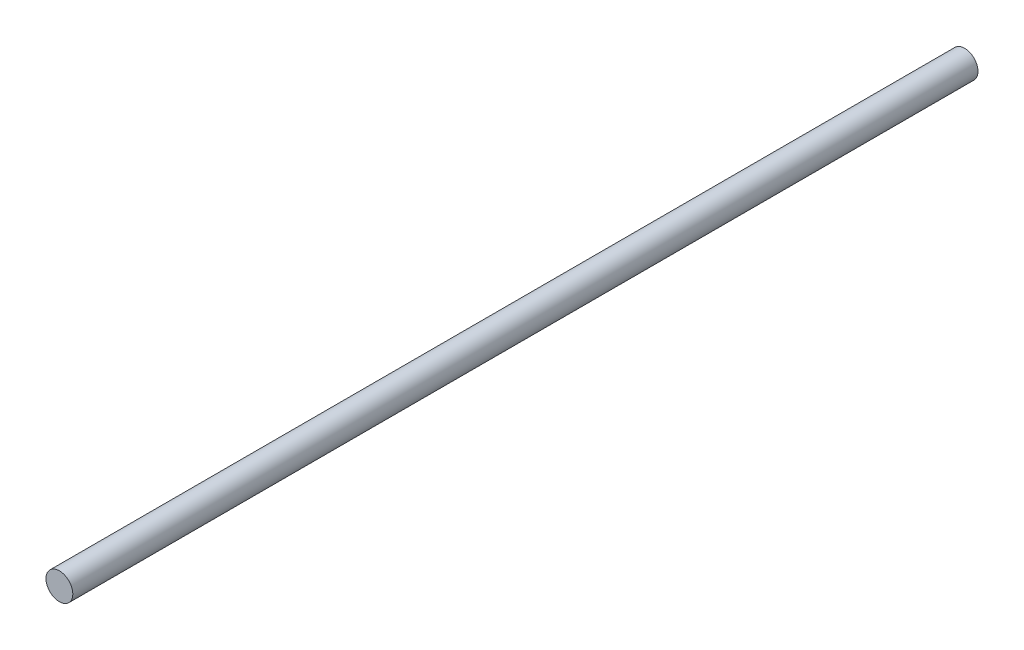
from build123d import *

# Parameters (mm, degrees)
ESQUISSE1_R        = 4
BOSS_EXTRU_1_DEPTH = 270


with BuildPart() as part:
    # Esquisse1 → Boss.-Extru.1 (new body)
    with BuildSketch(Plane.XY):
        Circle(ESQUISSE1_R)
    extrude(amount=BOSS_EXTRU_1_DEPTH)


solid = part.part
